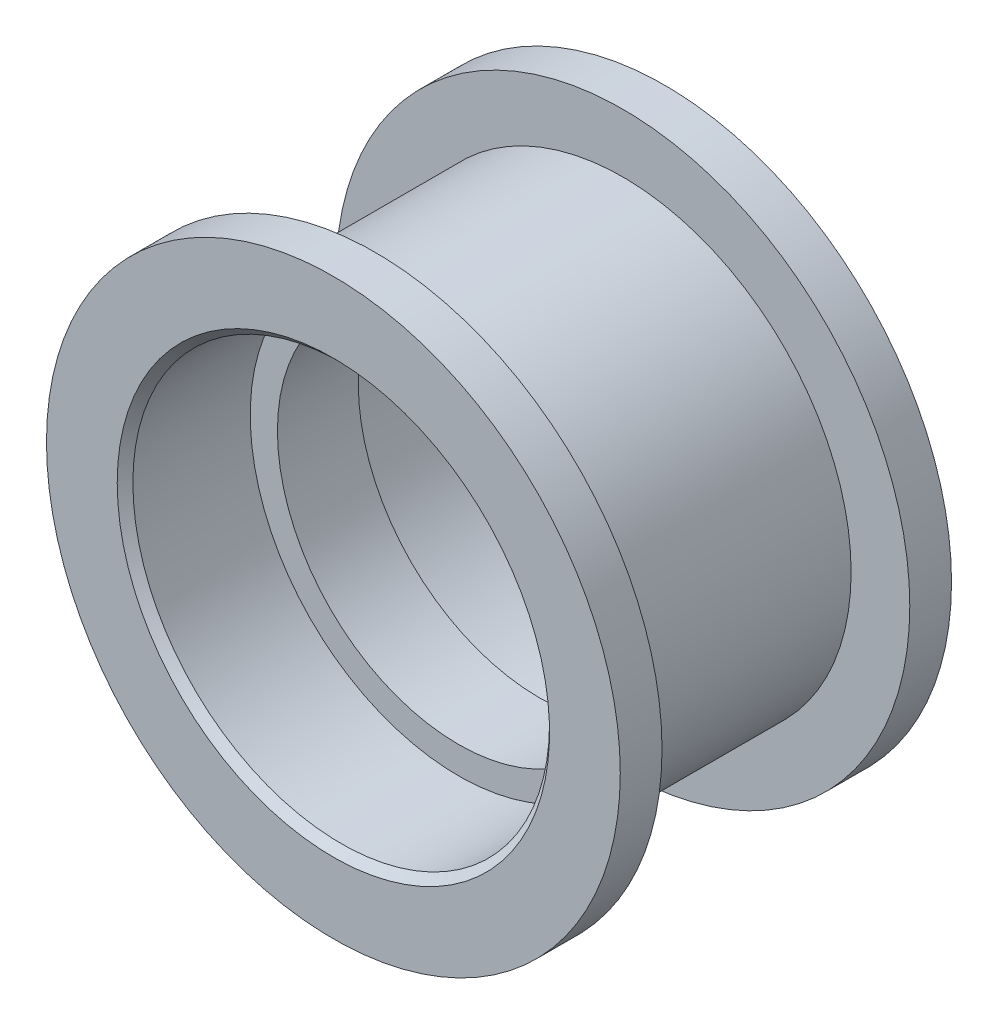
from build123d import *

# Parameters (mm, degrees)
CHAMFER1_SIZE = 0.3


with BuildPart() as part:
    # Sketch1 → Revolve1 (revolve)
    with BuildSketch(Plane(origin=(0, 0, 0), x_dir=(0, 0, -1), z_dir=(1, 0, 0))):
        Polygon((4.75, 8.75), (-4.75, 8.75), (-4.75, 11), (-6.35, 11), (-6.35, 7.9875), (-1.55, 7.9875), (-1.55, 6.945), (1.55, 6.945), (1.55, 7.9875), (6.35, 7.9875), (6.35, 11), (4.75, 11), align=None)
    revolve(axis=Axis((0, 0, 0), (0, 0, -1)))

    # Chamfer1
    chamfer1_edges = [part.edges().sort_by_distance(p)[0] for p in [
        (0, -7.9875, 6.35),
        (0, -7.9875, -6.35),
    ]]
    chamfer(chamfer1_edges, length=CHAMFER1_SIZE)


solid = part.part
